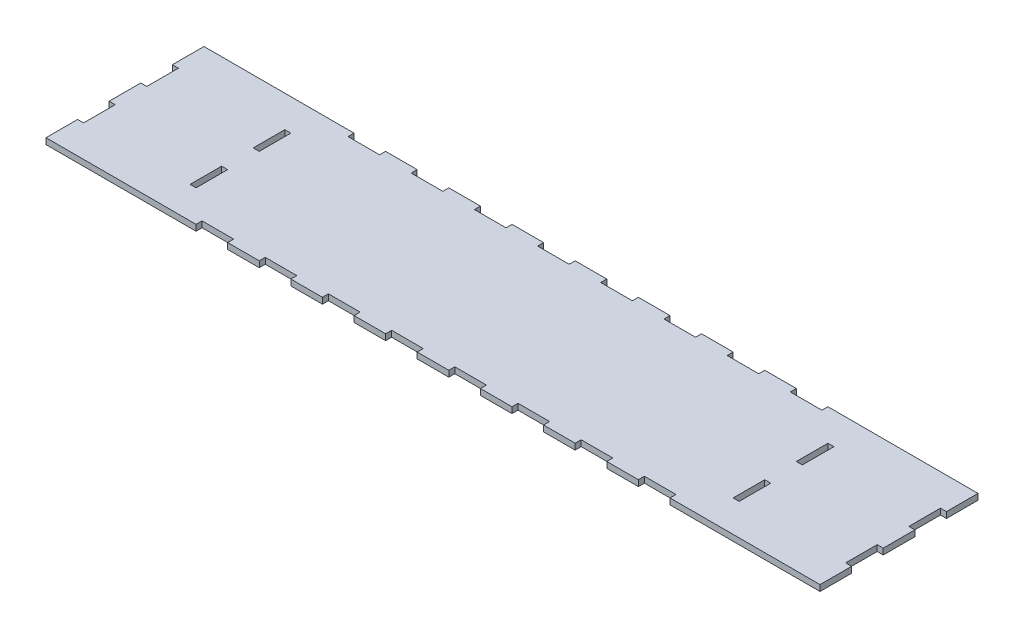
from build123d import *

# Parameters (mm, degrees)
SKETCH1_W           = 4.826
SKETCH1_H           = 25.4
BOSS_EXTRUDE1_DEPTH = 4.826
SKETCH2_W           = 25.4
SKETCH2_H           = 4.826
CUT_EXTRUDE1_DEPTH  = 5.826


with BuildPart() as part:
    # Sketch1 → Boss-Extrude1 (new body)
    with BuildSketch(Plane(origin=(0, 0, 0), x_dir=(1, 0, 0), z_dir=(0, 1, 0))):
        Polygon((0, 25.4), (0, 0), (622.3, 0), (622.3, 25.4), (617.474, 25.4), (617.474, 50.8), (622.3, 50.8), (622.3, 76.2), (617.474, 76.2), (617.474, 101.6), (622.3, 101.6), (622.3, 127), (0, 127), (0, 101.6), (4.826, 101.6), (4.826, 76.2), (0, 76.2), (0, 50.8), (4.826, 50.8), (4.826, 25.4), align=None)
        with Locations((92.837, 38.1)):
            Rectangle(SKETCH1_W, SKETCH1_H, mode=Mode.SUBTRACT)
        with Locations((529.463, 38.1)):
            Rectangle(SKETCH1_W, SKETCH1_H, mode=Mode.SUBTRACT)
        with Locations((92.837, 88.9)):
            Rectangle(SKETCH1_W, SKETCH1_H, mode=Mode.SUBTRACT)
        with Locations((529.463, 88.9)):
            Rectangle(SKETCH1_W, SKETCH1_H, mode=Mode.SUBTRACT)
    extrude(amount=BOSS_EXTRUDE1_DEPTH)

    # Sketch2 → Cut-Extrude1 (cut, through all)
    with BuildSketch(Plane(origin=(0, 4.826, 0), x_dir=(1, 0, 0), z_dir=(0, 1, 0))):
        with Locations((133.35, 124.587)):
            Rectangle(SKETCH2_W, SKETCH2_H)
        with Locations((184.15, 124.587)):
            Rectangle(SKETCH2_W, SKETCH2_H)
        with Locations((234.95, 124.587)):
            Rectangle(SKETCH2_W, SKETCH2_H)
        with Locations((285.75, 124.587)):
            Rectangle(SKETCH2_W, SKETCH2_H)
        with Locations((336.55, 124.587)):
            Rectangle(SKETCH2_W, SKETCH2_H)
        with Locations((387.35, 124.587)):
            Rectangle(SKETCH2_W, SKETCH2_H)
        with Locations((438.15, 124.587)):
            Rectangle(SKETCH2_W, SKETCH2_H)
        with Locations((488.95, 124.587)):
            Rectangle(SKETCH2_W, SKETCH2_H)
        with Locations((488.95, 2.413)):
            Rectangle(SKETCH2_W, SKETCH2_H)
        with Locations((438.15, 2.413)):
            Rectangle(SKETCH2_W, SKETCH2_H)
        with Locations((387.35, 2.413)):
            Rectangle(SKETCH2_W, SKETCH2_H)
        with Locations((336.55, 2.413)):
            Rectangle(SKETCH2_W, SKETCH2_H)
        with Locations((133.35, 2.413)):
            Rectangle(SKETCH2_W, SKETCH2_H)
        with Locations((184.15, 2.413)):
            Rectangle(SKETCH2_W, SKETCH2_H)
        with Locations((234.95, 2.413)):
            Rectangle(SKETCH2_W, SKETCH2_H)
        with Locations((285.75, 2.413)):
            Rectangle(SKETCH2_W, SKETCH2_H)
    extrude(amount=-CUT_EXTRUDE1_DEPTH, mode=Mode.SUBTRACT)


solid = part.part
